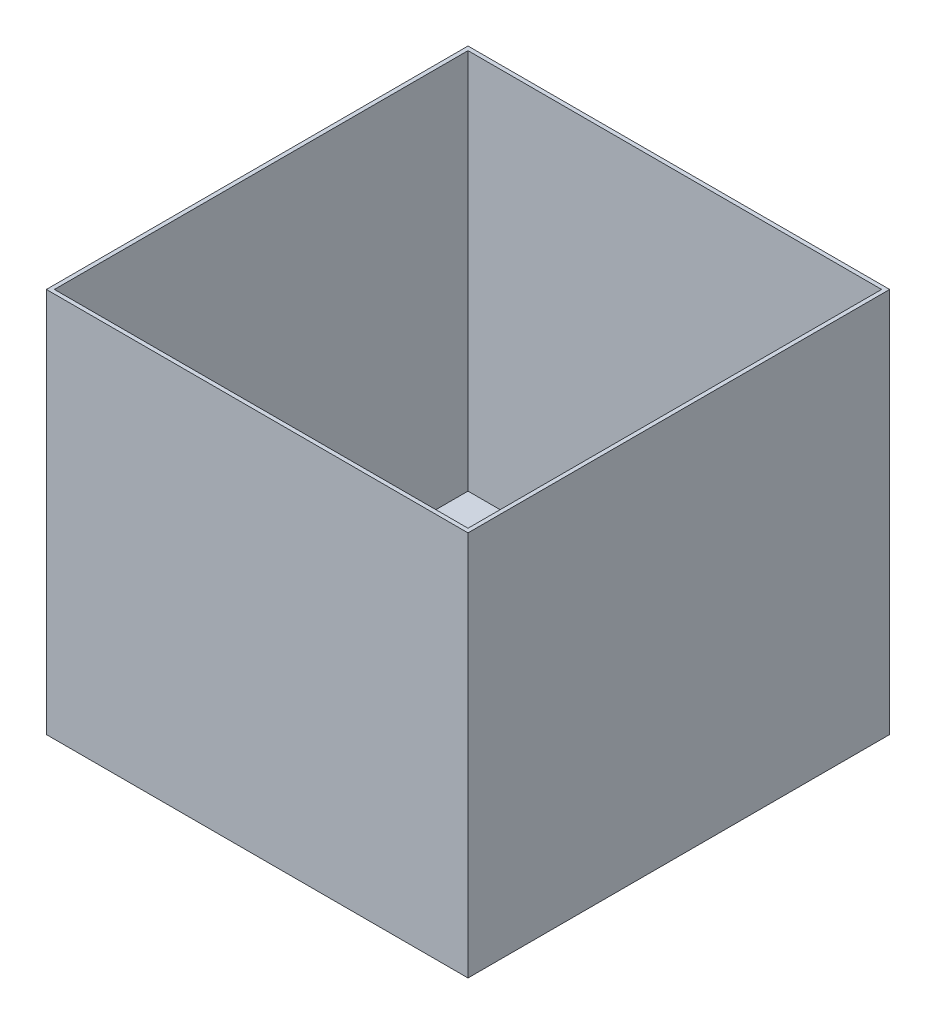
from build123d import *

# Parameters (mm, degrees)
SKETCH1_W           = 210
SKETCH1_H           = 192
BOSS_EXTRUDE1_DEPTH = 105
SKETCH2_W           = 206
SKETCH2_H           = 206
CUT_EXTRUDE1_DEPTH  = 190


with BuildPart() as part:
    # Sketch1 → Boss-Extrude1 (new body, symmetric)
    with BuildSketch(Plane.XY):
        Rectangle(SKETCH1_W, SKETCH1_H)
    extrude(amount=BOSS_EXTRUDE1_DEPTH, both=True)

    # Sketch2 → Cut-Extrude1 (cut)
    with BuildSketch(Plane(origin=(0, 96, 0), x_dir=(1, 0, 0), z_dir=(0, 1, 0))):
        Rectangle(SKETCH2_W, SKETCH2_H)
    extrude(amount=-CUT_EXTRUDE1_DEPTH, mode=Mode.SUBTRACT)


solid = part.part
